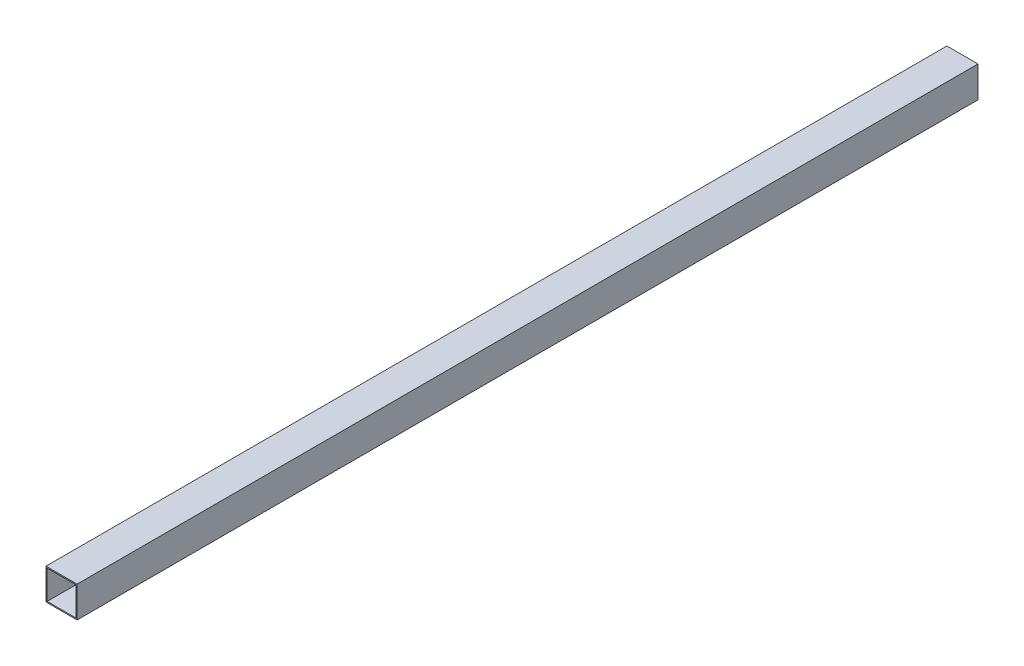
from build123d import *

# Parameters (mm, degrees)
ESBO_O1_W                = 40
ESBO_O1_H                = 40
RESSALTO_EXTRUS_O1_DEPTH = 1159
ESBO_O2_W                = 37
ESBO_O2_H                = 37
CORTE_EXTRUS_O1_DEPTH    = 1160


with BuildPart() as part:
    # Esboço1 → Ressalto-extrusão1 (new body)
    with BuildSketch(Plane.XY):
        Rectangle(ESBO_O1_W, ESBO_O1_H)
    extrude(amount=RESSALTO_EXTRUS_O1_DEPTH)

    # Esboço2 → Corte-extrusão1 (cut, through all)
    with BuildSketch(Plane.XY.offset(1159)):
        Rectangle(ESBO_O2_W, ESBO_O2_H)
    extrude(amount=-CORTE_EXTRUS_O1_DEPTH, mode=Mode.SUBTRACT)


solid = part.part
